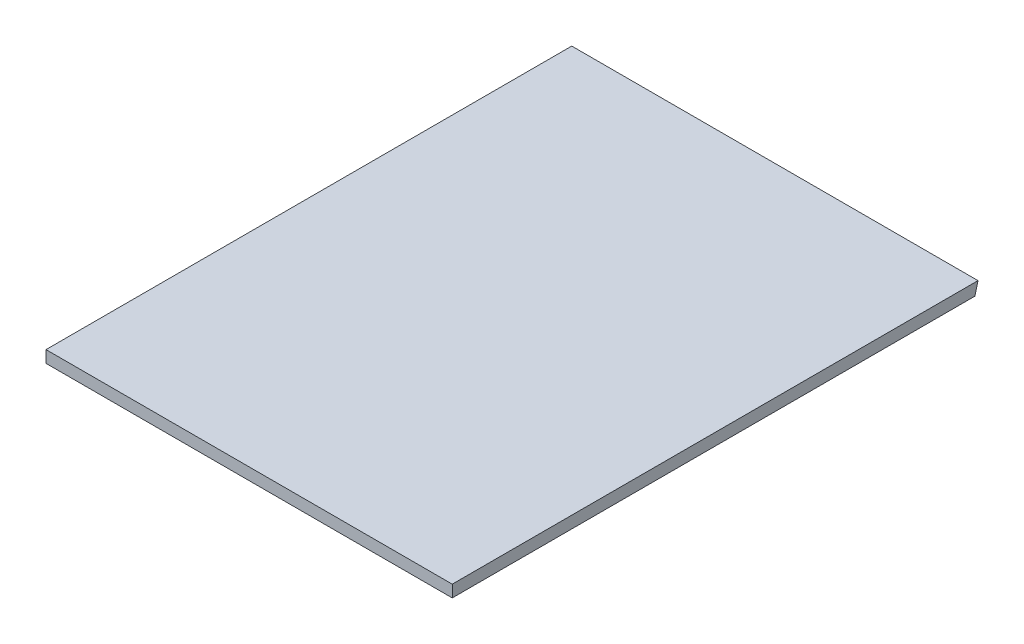
from build123d import *

# Parameters (mm, degrees)
CROQUIS1_W                 = 170
CROQUIS1_H                 = 220
SALIENTE_EXTRUIR1_DEPTH    = 5
CORTAR_EXTRUIR1_DEPTH      = 1
CORTAR_EXTRUIR1_DEPTH_BACK = 171


with BuildPart() as part:
    # Croquis1 → Saliente-Extruir1 (new body)
    with BuildSketch(Plane(origin=(0, 0, 0), x_dir=(1, 0, 0), z_dir=(0, 1, 0))):
        with Locations((-85, -98.968571429)):
            Rectangle(CROQUIS1_W, CROQUIS1_H)
    extrude(amount=SALIENTE_EXTRUIR1_DEPTH)

    # Croquis2 → Cortar-Extruir1 (cut, two sides)
    with BuildSketch(Plane(origin=(0, 0, 0), x_dir=(0, 0, -1), z_dir=(1, 0, 0))) as cortar_extruir1_sk:
        Polygon((125.582329234, 440.293422408), (11.031428571, 5), (7.736165295, -7.522000448), (-106.814735367, -442.815422855), (763.772109448, -671.91722418), (996.169174049, 211.191621083), align=None)
    extrude(amount=CORTAR_EXTRUIR1_DEPTH, mode=Mode.SUBTRACT)
    extrude(cortar_extruir1_sk.sketch, amount=-CORTAR_EXTRUIR1_DEPTH_BACK, mode=Mode.SUBTRACT)


solid = part.part
